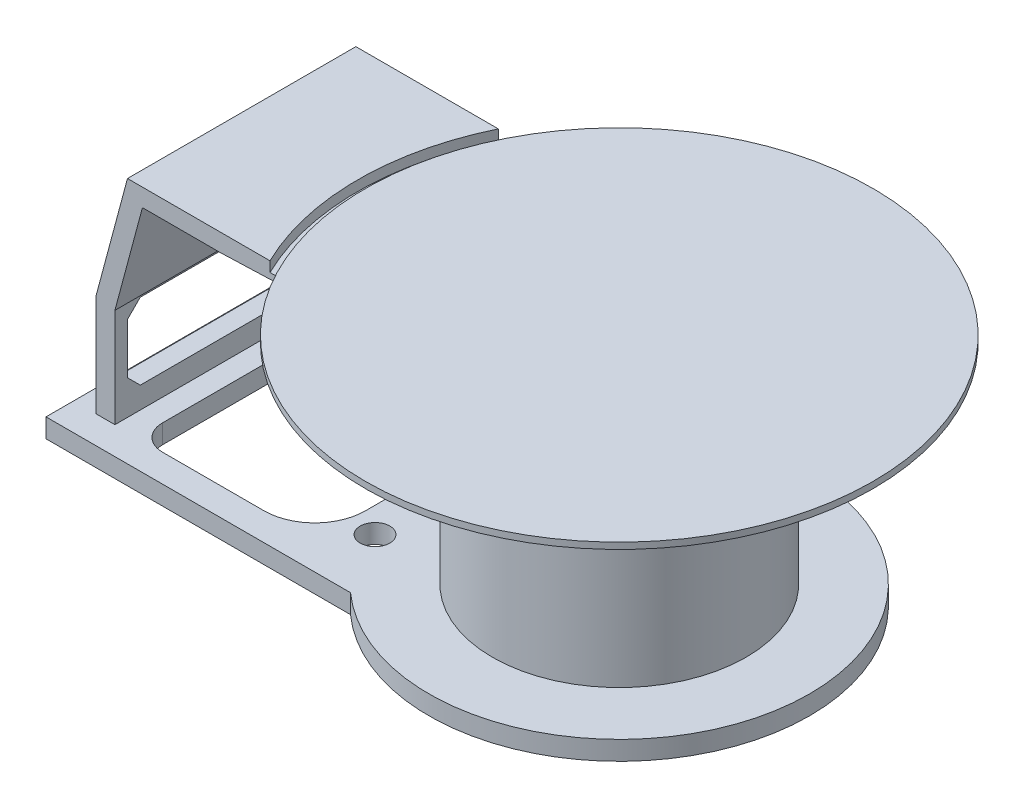
from build123d import *

# Parameters (mm, degrees)
SKETCH1_R               = 50
BOSS_EXTRUDE1_DEPTH     = 7.5
SKETCH1_2_R             = 50
BOSS_EXTRUDE2_DEPTH     = 90
SKETCH2_W               = 7.5
SKETCH2_H               = 90
BOSS_EXTRUDE3_DEPTH     = 40
SKETCH4_R               = 100
BOSS_EXTRUDE4_DEPTH     = 2.5
SKETCH7_W               = 90
SKETCH7_H               = 50
BOSS_EXTRUDE9_DEPTH     = 7.5
CUT_EXTRUDE1_REACH      = 297.683
SKETCH14_W              = 95
SKETCH14_H              = 90
BOSS_EXTRUDE13_DEPTH    = 3
BOSS_EXTRUDE14_DEPTH    = 5
CUT_EXTRUDE3_DEPTH      = 5
CUT_EXTRUDE3_DEPTH_BACK = 1
SKETCH17_W              = 70.898930346
SKETCH17_H              = 90
CHAMFER3_SIZE           = 2
CHAMFER3_SIZE2          = 57.272506566
SCALE1_SCALE            = 0.3
CUT_EXTRUDE4_REACH      = 75.595
SKETCH19_R              = 1.75


with BuildPart() as part:
    # Sketch1 → Boss-Extrude1 (new body)
    with BuildSketch(Plane(origin=(0, 0, 0), x_dir=(1, 0, 0), z_dir=(0, 1, 0))):
        with BuildLine():
            Line((-50, 55.901699437), (-170, 55.901699437))
            Line((-170, 55.901699437), (-170, -55.901699437))
            Line((-170, -55.901699437), (-50, -55.901699437))
            ThreePointArc((-50, -55.901699437), (75, 0), (-50, 55.901699437))
        make_face()
        Circle(SKETCH1_R, mode=Mode.SUBTRACT)
        with BuildLine():
            Line((-95, -45), (-135, -45))
            ThreePointArc((-135, -45), (-142.071067812, -42.071067812), (-145, -35))
            Line((-145, -35), (-145, 35))
            ThreePointArc((-145, 35), (-142.071067812, 42.071067812), (-135, 45))
            Line((-135, 45), (-95, 45))
            ThreePointArc((-95, 45), (-80.857864376, 39.142135624), (-75, 25))
            Line((-75, 25), (-75, -25))
            ThreePointArc((-75, -25), (-80.857864376, -39.142135624), (-95, -45))
        make_face(mode=Mode.SUBTRACT)
    extrude(amount=BOSS_EXTRUDE1_DEPTH)

    # Sketch1_2 → Boss-Extrude2 (add)
    with BuildSketch(Plane(origin=(0, 0, 0), x_dir=(1, 0, 0), z_dir=(0, 1, 0))):
        Circle(SKETCH1_2_R)
    extrude(amount=BOSS_EXTRUDE2_DEPTH)

    # Sketch2 → Boss-Extrude3 (add)
    with BuildSketch(Plane(origin=(0, 7.5, 0), x_dir=(1, 0, 0), z_dir=(0, 1, 0))):
        with Locations((-157.5, 0)):
            Rectangle(SKETCH2_W, SKETCH2_H)
    extrude(amount=BOSS_EXTRUDE3_DEPTH)

    # Sketch4 → Boss-Extrude4 (add)
    with BuildSketch(Plane(origin=(0, 90, 0), x_dir=(1, 0, 0), z_dir=(0, 1, 0))):
        Circle(SKETCH4_R)
    extrude(amount=BOSS_EXTRUDE4_DEPTH)

    # Sketch7 → Boss-Extrude9 (add)
    with BuildSketch(Plane(origin=(-162.32329818, 43.49439666, 0), x_dir=(0, 0, 1), z_dir=(-0.9659258262890691, 0.2588190451025179, 0))):
        with Locations((0, 29.146905726)):
            Rectangle(SKETCH7_W, SKETCH7_H)
    extrude(amount=-BOSS_EXTRUDE9_DEPTH)

    # Sketch3 → Cut-Extrude1 (cut, up to next)
    with BuildSketch(Plane.ZY.offset(161.25), mode=Mode.PRIVATE) as cut_extrude1_sk1:
        Polygon((35, 46), (40, 41), (40, 21), (35, 16), (-35, 16), (-40, 21), (-40, 41), (-35, 46), align=None)
    cut_extrude1_tool1 = extrude(cut_extrude1_sk1.sketch, amount=-CUT_EXTRUDE1_REACH, mode=Mode.PRIVATE) & part.part
    add(cut_extrude1_tool1.solids().sort_by_distance((-161.25, 31, 0))[0], mode=Mode.SUBTRACT)

    # Sketch14 → Boss-Extrude13 (add)
    with BuildSketch(Plane.XZ.offset(-90)):
        with Locations((-102.34127557, 0)):
            Rectangle(SKETCH14_W, SKETCH14_H)
    extrude(amount=BOSS_EXTRUDE13_DEPTH)

    # Sketch15 → Boss-Extrude14 (add)
    with BuildSketch(Plane(origin=(0, 90, 0), x_dir=(1, 0, 0), z_dir=(0, 1, 0))):
        with BuildLine():
            Line((-92.649878575, 45), (-144.686825896, 45))
            Line((-144.686825896, 45), (-144.686825896, -45))
            Line((-144.686825896, -45), (-92.649878575, -45))
            ThreePointArc((-92.649878575, -45), (-103, 0), (-92.649878575, 45))
        make_face()
    extrude(amount=BOSS_EXTRUDE14_DEPTH)

    # Sketch17 → Cut-Extrude3 (cut, two sides: drawn at the far end of the back side and taken through both)
    with BuildSketch(Plane(origin=(0, 95, 0), x_dir=(1, 0, 0), z_dir=(0, 1, 0)).offset(-CUT_EXTRUDE3_DEPTH_BACK)):
        with Locations((-122.050534827, 0)):
            Rectangle(SKETCH17_W, SKETCH17_H)
    extrude(amount=CUT_EXTRUDE3_DEPTH + CUT_EXTRUDE3_DEPTH_BACK, mode=Mode.SUBTRACT)

    # Chamfer3
    chamfer3_edges = [part.edges().sort_by_distance(p)[0] for p in [
        (-54.84127557, 87, 0),
    ]]
    chamfer3_side = [part.faces().sort_by_distance(p)[0] for p in [
        (-54.84127557, 88.5, 0),
    ]]
    chamfer(chamfer3_edges, length=CHAMFER3_SIZE, length2=CHAMFER3_SIZE2, reference=chamfer3_side[0])


with BuildPart() as part_1:
    # Scale1: scaled about (-15.701446572, 46.083241644, 0)
    add(part.part.scale(SCALE1_SCALE).moved(Location((-10.9910126, 32.258269151, 0))))

    # Sketch19 → Cut-Extrude4 (cut, up to next)
    with BuildSketch(Plane(origin=(0, 34.50826915, 0), x_dir=(1, 0, 0), z_dir=(0, 1, 0)), mode=Mode.PRIVATE) as cut_extrude4_sk1:
        with Locations((-30.491012601, 9.375)):
            Circle(SKETCH19_R)
    cut_extrude4_tool1 = extrude(cut_extrude4_sk1.sketch, amount=-CUT_EXTRUDE4_REACH, mode=Mode.PRIVATE) & part_1.part
    # Sketch19 → Cut-Extrude4 (cut, up to next)
    with BuildSketch(Plane(origin=(0, 34.50826915, 0), x_dir=(1, 0, 0), z_dir=(0, 1, 0)), mode=Mode.PRIVATE) as cut_extrude4_sk2:
        with Locations((-30.491012601, -9.375)):
            Circle(SKETCH19_R)
    cut_extrude4_tool2 = extrude(cut_extrude4_sk2.sketch, amount=-CUT_EXTRUDE4_REACH, mode=Mode.PRIVATE) & part_1.part
    add(cut_extrude4_tool1.solids().sort_by_distance((-30.491013, 34.508269, -9.375))[0], mode=Mode.SUBTRACT)
    add(cut_extrude4_tool2.solids().sort_by_distance((-30.491013, 34.508269, 9.375))[0], mode=Mode.SUBTRACT)


solid = part_1.part
